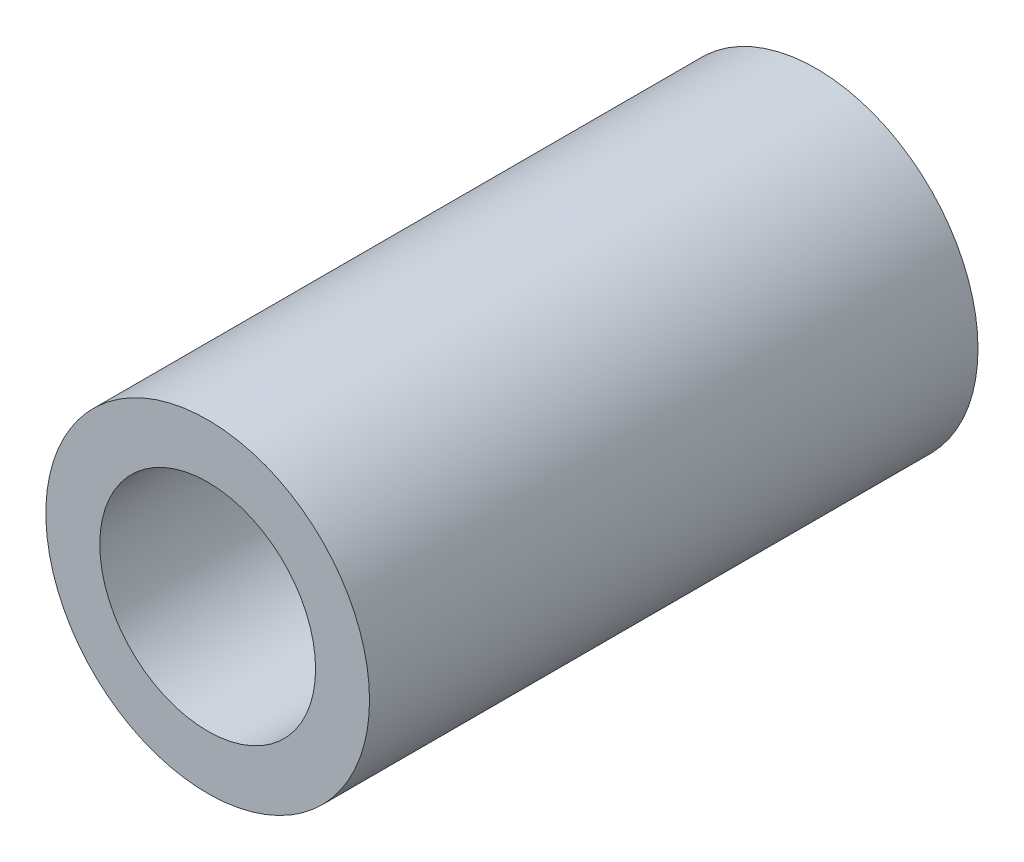
from build123d import *

# Parameters (mm, degrees)
SKETCH1_R           = 19.05
SKETCH1_R_2         = 12.7
BOSS_EXTRUDE1_DEPTH = 71.628


with BuildPart() as part:
    # Sketch1 → Boss-Extrude1 (new body)
    with BuildSketch(Plane.XY):
        Circle(SKETCH1_R)
        Circle(SKETCH1_R_2, mode=Mode.SUBTRACT)
    extrude(amount=BOSS_EXTRUDE1_DEPTH)


solid = part.part
